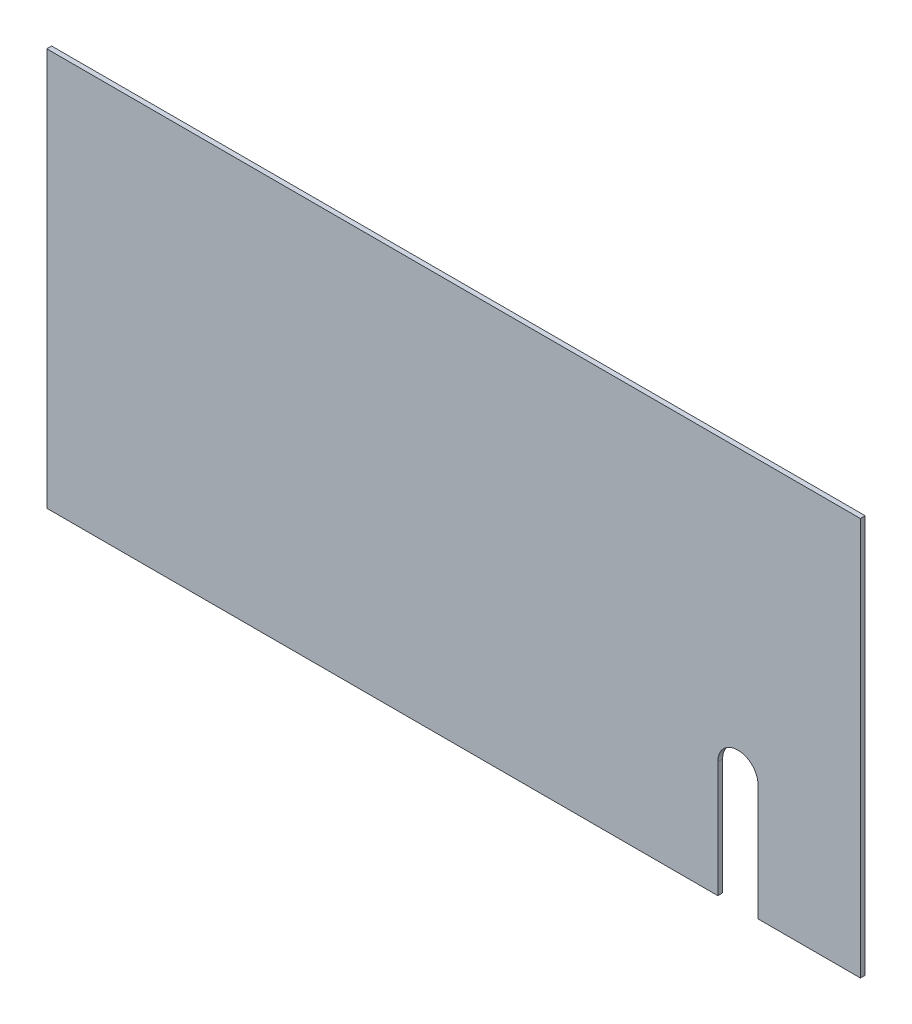
from build123d import *

# Parameters (mm, degrees)
ESQUISSE1_W             = 505
ESQUISSE1_H             = 247
BOSS_EXTRU_1_DEPTH      = 3
ENL_V_MAT_EXTRU_2_DEPTH = 72


with BuildPart() as part:
    # Esquisse1 → Boss.-Extru.1 (new body)
    with BuildSketch(Plane.XY):
        with Locations((-22, 121.33382636)):
            Rectangle(ESQUISSE1_W, ESQUISSE1_H)
    extrude(amount=BOSS_EXTRU_1_DEPTH)

    # Esquisse3 → Enlèv. mat.-Extru.2 (cut)
    with BuildSketch(Plane.XY.offset(3)):
        with BuildLine():
            Line((142, 69.83382636), (142, -28.16617364))
            Line((142, -28.16617364), (167, -28.16617364))
            Line((167, -28.16617364), (167, 69.83382636))
            ThreePointArc((167, 69.83382636), (154.5, 82.33382636), (142, 69.83382636))
        make_face()
    extrude(amount=-ENL_V_MAT_EXTRU_2_DEPTH, mode=Mode.SUBTRACT)


solid = part.part
